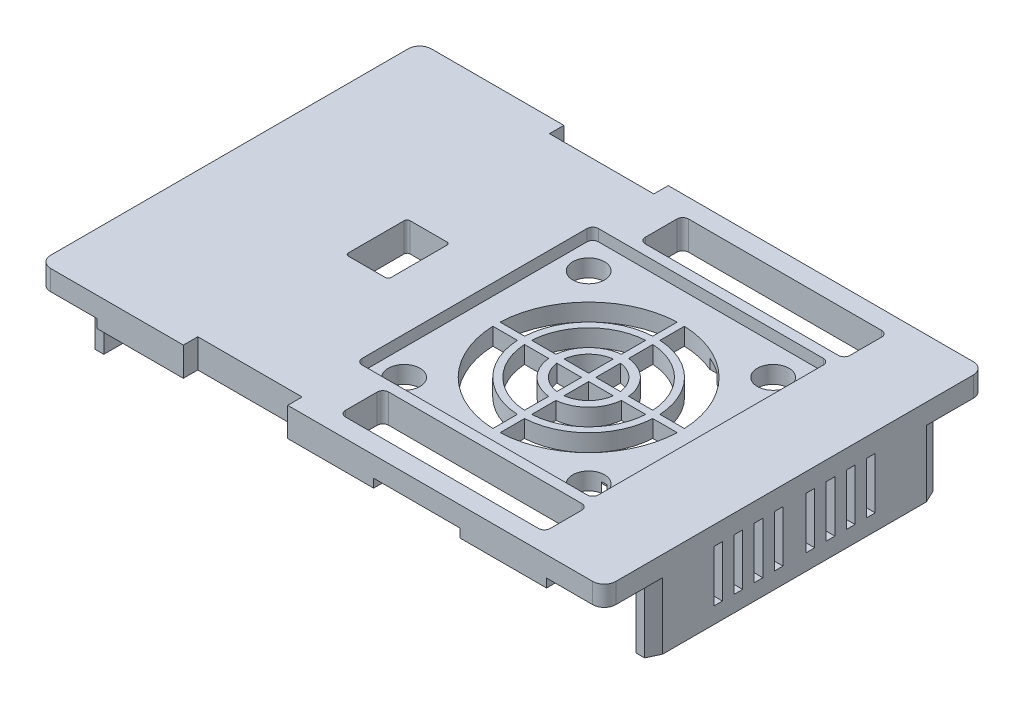
from build123d import *

# Parameters (mm, degrees)
SKETCH1_W             = 98
SKETCH1_H             = 66
BOSS_EXTRUDE1_DEPTH   = 5
SKETCH2_W             = 18.1
SKETCH2_H             = 2.5
SKETCH2_W_2           = 15
CUT_EXTRUDE1_DEPTH    = 1.5
FILLET1_R             = 2
CUT_EXTRUDE2_DEPTH    = 2
CUT_EXTRUDE3_REACH    = 5
SKETCH4_R             = 2.75
CUT_EXTRUDE4_REACH    = 7
CHAMFER1_SIZE         = 1
CHAMFER1_SIZE2        = 2.144506921
CHAMFER1_PART_2_SIZE  = 1
CHAMFER1_PART_2_SIZE2 = 2.144506921
CHAMFER1_PART_3_SIZE  = 1
CHAMFER1_PART_3_SIZE2 = 2.144506921
CHAMFER1_PART_4_SIZE  = 1
CHAMFER1_PART_4_SIZE2 = 2.144506921
BOSS_EXTRUDE2_DEPTH   = 12
FILLET2_R             = 1
BOSS_EXTRUDE3_DEPTH   = 10
CUT_EXTRUDE5_REACH    = 100
SKETCH8_W             = 1.5
SKETCH8_H             = 8.931107371
CUT_EXTRUDE6_REACH    = 19
CUT_EXTRUDE7_REACH    = 100
SKETCH10_W            = 1.5
SKETCH10_H            = 9
SKETCH13_W            = 18.1
SKETCH13_H            = 2.5
CUT_EXTRUDE9_DEPTH    = 3.5


with BuildPart() as part:
    # Sketch1 → Boss-Extrude1 (new body)
    with BuildSketch(Plane(origin=(0, 0, 0), x_dir=(1, 0, 0), z_dir=(0, 1, 0))):
        Rectangle(SKETCH1_W, SKETCH1_H)
    extrude(amount=BOSS_EXTRUDE1_DEPTH)

    # Sketch2 → Cut-Extrude1 (cut)
    with BuildSketch(Plane.XZ):
        Polygon((-39, 33), (-39, 30.5), (-46.5, 30.5), (-46.5, 24.3), (-49, 24.3), (-49, 33), align=None)
        Polygon((-46.5, -30.5), (-39, -30.5), (-39, -33), (-49, -33), (-49, -24.3), (-46.5, -24.3), align=None)
        Polygon((46.5, -30.5), (46.5, -25), (49, -25), (49, -33), (39, -33), (39, -30.5), align=None)
        with Locations((-14.95, 31.75)):
            Rectangle(SKETCH2_W, SKETCH2_H)
        with Locations((16.5, 31.75)):
            Rectangle(SKETCH2_W_2, SKETCH2_H)
        Polygon((49, 33), (39, 33), (39, 30.5), (46.5, 30.5), (46.5, 25), (49, 25), align=None)
        with Locations((16.5, -31.75)):
            Rectangle(SKETCH2_W_2, SKETCH2_H)
        with Locations((-14.95, -31.75)):
            Rectangle(SKETCH2_W, SKETCH2_H)
    extrude(amount=-CUT_EXTRUDE1_DEPTH, mode=Mode.SUBTRACT)

    # Fillet1
    fillet1_edges = [part.edges().sort_by_distance(p)[0] for p in [
        (49, 3.25, 33),
        (-49, 3.25, 33),
        (-49, 3.25, -33),
        (49, 3.25, -33),
    ]]
    fillet(fillet1_edges, radius=FILLET1_R)

    # Sketch3 → Cut-Extrude2 (cut)
    with BuildSketch(Plane(origin=(0, 5, 0), x_dir=(1, 0, 0), z_dir=(0, 1, 0))):
        with BuildLine():
            Line((-5.5, -20.5), (33.5, -20.5))
            ThreePointArc((33.5, -20.5), (34.207106781, -20.207106781), (34.5, -19.5))
            Line((34.5, -19.5), (34.5, 19.5))
            ThreePointArc((34.5, 19.5), (34.207106781, 20.207106781), (33.5, 20.5))
            Line((33.5, 20.5), (-5.5, 20.5))
            ThreePointArc((-5.5, 20.5), (-6.207106781, 20.207106781), (-6.5, 19.5))
            Line((-6.5, 19.5), (-6.5, -19.5))
            ThreePointArc((-6.5, -19.5), (-6.207106781, -20.207106781), (-5.5, -20.5))
        make_face()
    extrude(amount=-CUT_EXTRUDE2_DEPTH, mode=Mode.SUBTRACT)

    # Sketch4 → Cut-Extrude3 (cut, up to next)
    with BuildSketch(Plane(origin=(0, 3, 0), x_dir=(1, 0, 0), z_dir=(0, 1, 0)), mode=Mode.PRIVATE) as cut_extrude3_sk1:
        with Locations((30, 15.293471802)):
            Circle(SKETCH4_R)
    cut_extrude3_tool1 = extrude(cut_extrude3_sk1.sketch, amount=-CUT_EXTRUDE3_REACH, mode=Mode.PRIVATE) & part.part
    add(cut_extrude3_tool1.solids().sort_by_distance((30, 3, -15.293472))[0], mode=Mode.SUBTRACT)
    # Sketch4 → Cut-Extrude3 (cut, up to next)
    with BuildSketch(Plane(origin=(0, 3, 0), x_dir=(1, 0, 0), z_dir=(0, 1, 0)), mode=Mode.PRIVATE) as cut_extrude3_sk2:
        with Locations((30, -16.706528198)):
            Circle(SKETCH4_R)
    cut_extrude3_tool2 = extrude(cut_extrude3_sk2.sketch, amount=-CUT_EXTRUDE3_REACH, mode=Mode.PRIVATE) & part.part
    add(cut_extrude3_tool2.solids().sort_by_distance((30, 3, 16.706528))[0], mode=Mode.SUBTRACT)
    # Sketch4 → Cut-Extrude3 (cut, up to next)
    with BuildSketch(Plane(origin=(0, 3, 0), x_dir=(1, 0, 0), z_dir=(0, 1, 0)), mode=Mode.PRIVATE) as cut_extrude3_sk3:
        with Locations((-2, -16.706528198)):
            Circle(SKETCH4_R)
    cut_extrude3_tool3 = extrude(cut_extrude3_sk3.sketch, amount=-CUT_EXTRUDE3_REACH, mode=Mode.PRIVATE) & part.part
    add(cut_extrude3_tool3.solids().sort_by_distance((-2, 3, 16.706528))[0], mode=Mode.SUBTRACT)
    # Sketch4 → Cut-Extrude3 (cut, up to next)
    with BuildSketch(Plane(origin=(0, 3, 0), x_dir=(1, 0, 0), z_dir=(0, 1, 0)), mode=Mode.PRIVATE) as cut_extrude3_sk4:
        with Locations((-2, 15.293471802)):
            Circle(SKETCH4_R)
    cut_extrude3_tool4 = extrude(cut_extrude3_sk4.sketch, amount=-CUT_EXTRUDE3_REACH, mode=Mode.PRIVATE) & part.part
    add(cut_extrude3_tool4.solids().sort_by_distance((-2, 3, -15.293472))[0], mode=Mode.SUBTRACT)
    # Sketch4 → Cut-Extrude3 (cut, up to next)
    with BuildSketch(Plane(origin=(0, 3, 0), x_dir=(1, 0, 0), z_dir=(0, 1, 0)), mode=Mode.PRIVATE) as cut_extrude3_sk5:
        with BuildLine():
            Line((13.375, 5.603830139), (13.375, 9.803003365))
            ThreePointArc((13.375, 9.803003365), (6.554986366, 6.737439203), (3.490380704, -0.083005192))
            Line((3.490380704, -0.083005192), (7.689495551, -0.083005192))
            ThreePointArc((7.689495551, -0.083005192), (9.515545796, 3.776876516), (13.375, 5.603830139))
        make_face()
    cut_extrude3_tool5 = extrude(cut_extrude3_sk5.sketch, amount=-CUT_EXTRUDE3_REACH, mode=Mode.PRIVATE) & part.part
    add(cut_extrude3_tool5.solids().sort_by_distance((8.40392, 3, -4.888591))[0], mode=Mode.SUBTRACT)
    # Sketch4 → Cut-Extrude3 (cut, up to next)
    with BuildSketch(Plane(origin=(0, 3, 0), x_dir=(1, 0, 0), z_dir=(0, 1, 0)), mode=Mode.PRIVATE) as cut_extrude3_sk6:
        with BuildLine():
            Line((14.625, 11.037854092), (14.625, 15.28126011))
            ThreePointArc((14.625, 15.28126011), (25.314231081, 10.606657695), (29.987845979, -0.083005192))
            Line((29.987845979, -0.083005192), (25.744460798, -0.083005192))
            ThreePointArc((25.744460798, -0.083005192), (22.316806353, 7.609232288), (14.625, 11.037854092))
        make_face()
    cut_extrude3_tool6 = extrude(cut_extrude3_sk6.sketch, amount=-CUT_EXTRUDE3_REACH, mode=Mode.PRIVATE) & part.part
    add(cut_extrude3_tool6.solids().sort_by_distance((23.015818, 3, -8.308337))[0], mode=Mode.SUBTRACT)
    # Sketch4 → Cut-Extrude3 (cut, up to next)
    with BuildSketch(Plane(origin=(0, 3, 0), x_dir=(1, 0, 0), z_dir=(0, 1, 0)), mode=Mode.PRIVATE) as cut_extrude3_sk7:
        with BuildLine():
            Line((13.375, 11.037854092), (13.375, 15.28126011))
            ThreePointArc((13.375, 15.28126011), (2.685768919, 10.606657695), (-1.987845979, -0.083005192))
            Line((-1.987845979, -0.083005192), (2.255539202, -0.083005192))
            ThreePointArc((2.255539202, -0.083005192), (5.683193647, 7.609232288), (13.375, 11.037854092))
        make_face()
    cut_extrude3_tool7 = extrude(cut_extrude3_sk7.sketch, amount=-CUT_EXTRUDE3_REACH, mode=Mode.PRIVATE) & part.part
    add(cut_extrude3_tool7.solids().sort_by_distance((4.984182, 3, -8.308337))[0], mode=Mode.SUBTRACT)
    # Sketch4 → Cut-Extrude3 (cut, up to next)
    with BuildSketch(Plane(origin=(0, 3, 0), x_dir=(1, 0, 0), z_dir=(0, 1, 0)), mode=Mode.PRIVATE) as cut_extrude3_sk8:
        with BuildLine():
            Line((20.310504449, -0.083005192), (24.509619296, -0.083005192))
            ThreePointArc((24.509619296, -0.083005192), (21.445013634, 6.737439203), (14.625, 9.803003365))
            Line((14.625, 9.803003365), (14.625, 5.603830139))
            ThreePointArc((14.625, 5.603830139), (18.484454204, 3.776876516), (20.310504449, -0.083005192))
        make_face()
    cut_extrude3_tool8 = extrude(cut_extrude3_sk8.sketch, amount=-CUT_EXTRUDE3_REACH, mode=Mode.PRIVATE) & part.part
    add(cut_extrude3_tool8.solids().sort_by_distance((19.59608, 3, -4.888591))[0], mode=Mode.SUBTRACT)
    # Sketch4 → Cut-Extrude3 (cut, up to next)
    with BuildSketch(Plane(origin=(0, 3, 0), x_dir=(1, 0, 0), z_dir=(0, 1, 0)), mode=Mode.PRIVATE) as cut_extrude3_sk9:
        with BuildLine():
            Line((20.310504449, -1.330051205), (24.509619296, -1.330051205))
            ThreePointArc((24.509619296, -1.330051205), (21.445013634, -8.150495599), (14.625, -11.216059762))
            Line((14.625, -11.216059762), (14.625, -7.016886536))
            ThreePointArc((14.625, -7.016886536), (18.484454204, -5.189932913), (20.310504449, -1.330051205))
        make_face()
    cut_extrude3_tool9 = extrude(cut_extrude3_sk9.sketch, amount=-CUT_EXTRUDE3_REACH, mode=Mode.PRIVATE) & part.part
    add(cut_extrude3_tool9.solids().sort_by_distance((19.59608, 3, 6.301647))[0], mode=Mode.SUBTRACT)
    # Sketch4 → Cut-Extrude3 (cut, up to next)
    with BuildSketch(Plane(origin=(0, 3, 0), x_dir=(1, 0, 0), z_dir=(0, 1, 0)), mode=Mode.PRIVATE) as cut_extrude3_sk10:
        with BuildLine():
            Line((14.625, -0.083005192), (18.894017005, -0.083005192))
            ThreePointArc((18.894017005, -0.083005192), (17.489092238, 2.781511185), (14.625, 4.187300403))
            Line((14.625, 4.187300403), (14.625, -0.083005192))
        make_face()
    cut_extrude3_tool10 = extrude(cut_extrude3_sk10.sketch, amount=-CUT_EXTRUDE3_REACH, mode=Mode.PRIVATE) & part.part
    add(cut_extrude3_tool10.solids().sort_by_distance((16.367856, 3, -1.66032))[0], mode=Mode.SUBTRACT)
    # Sketch4 → Cut-Extrude3 (cut, up to next)
    with BuildSketch(Plane(origin=(0, 3, 0), x_dir=(1, 0, 0), z_dir=(0, 1, 0)), mode=Mode.PRIVATE) as cut_extrude3_sk11:
        with BuildLine():
            Line((14.625, -1.330051205), (18.894017005, -1.330051205))
            ThreePointArc((18.894017005, -1.330051205), (17.489092238, -4.194567581), (14.625, -5.6003568))
            Line((14.625, -5.6003568), (14.625, -1.330051205))
        make_face()
    cut_extrude3_tool11 = extrude(cut_extrude3_sk11.sketch, amount=-CUT_EXTRUDE3_REACH, mode=Mode.PRIVATE) & part.part
    add(cut_extrude3_tool11.solids().sort_by_distance((16.367856, 3, 3.073376))[0], mode=Mode.SUBTRACT)
    # Sketch4 → Cut-Extrude3 (cut, up to next)
    with BuildSketch(Plane(origin=(0, 3, 0), x_dir=(1, 0, 0), z_dir=(0, 1, 0)), mode=Mode.PRIVATE) as cut_extrude3_sk12:
        with BuildLine():
            Line((25.744460798, -1.330051205), (29.987845979, -1.330051205))
            ThreePointArc((29.987845979, -1.330051205), (25.314231081, -12.019714091), (14.625, -16.694316507))
            Line((14.625, -16.694316507), (14.625, -12.450910488))
            ThreePointArc((14.625, -12.450910488), (22.316806353, -9.022288685), (25.744460798, -1.330051205))
        make_face()
    cut_extrude3_tool12 = extrude(cut_extrude3_sk12.sketch, amount=-CUT_EXTRUDE3_REACH, mode=Mode.PRIVATE) & part.part
    add(cut_extrude3_tool12.solids().sort_by_distance((23.015818, 3, 9.721394))[0], mode=Mode.SUBTRACT)
    # Sketch4 → Cut-Extrude3 (cut, up to next)
    with BuildSketch(Plane(origin=(0, 3, 0), x_dir=(1, 0, 0), z_dir=(0, 1, 0)), mode=Mode.PRIVATE) as cut_extrude3_sk13:
        with BuildLine():
            Line((13.375, -16.694316507), (13.375, -12.450910488))
            ThreePointArc((13.375, -12.450910488), (5.683193647, -9.022288685), (2.255539202, -1.330051205))
            Line((2.255539202, -1.330051205), (-1.987845979, -1.330051205))
            ThreePointArc((-1.987845979, -1.330051205), (2.685768919, -12.019714091), (13.375, -16.694316507))
        make_face()
    cut_extrude3_tool13 = extrude(cut_extrude3_sk13.sketch, amount=-CUT_EXTRUDE3_REACH, mode=Mode.PRIVATE) & part.part
    add(cut_extrude3_tool13.solids().sort_by_distance((4.984182, 3, 9.721394))[0], mode=Mode.SUBTRACT)
    # Sketch4 → Cut-Extrude3 (cut, up to next)
    with BuildSketch(Plane(origin=(0, 3, 0), x_dir=(1, 0, 0), z_dir=(0, 1, 0)), mode=Mode.PRIVATE) as cut_extrude3_sk14:
        with BuildLine():
            Line((3.490380704, -1.330051205), (7.689495551, -1.330051205))
            ThreePointArc((7.689495551, -1.330051205), (9.515545796, -5.189932913), (13.375, -7.016886536))
            Line((13.375, -7.016886536), (13.375, -11.216059762))
            ThreePointArc((13.375, -11.216059762), (6.554986366, -8.150495599), (3.490380704, -1.330051205))
        make_face()
    cut_extrude3_tool14 = extrude(cut_extrude3_sk14.sketch, amount=-CUT_EXTRUDE3_REACH, mode=Mode.PRIVATE) & part.part
    add(cut_extrude3_tool14.solids().sort_by_distance((8.40392, 3, 6.301647))[0], mode=Mode.SUBTRACT)
    # Sketch4 → Cut-Extrude3 (cut, up to next)
    with BuildSketch(Plane(origin=(0, 3, 0), x_dir=(1, 0, 0), z_dir=(0, 1, 0)), mode=Mode.PRIVATE) as cut_extrude3_sk15:
        with BuildLine():
            Line((9.105982995, -0.083005192), (13.375, -0.083005192))
            Line((13.375, -0.083005192), (13.375, 4.187300403))
            ThreePointArc((13.375, 4.187300403), (10.510907762, 2.781511185), (9.105982995, -0.083005192))
        make_face()
    cut_extrude3_tool15 = extrude(cut_extrude3_sk15.sketch, amount=-CUT_EXTRUDE3_REACH, mode=Mode.PRIVATE) & part.part
    add(cut_extrude3_tool15.solids().sort_by_distance((11.632144, 3, -1.66032))[0], mode=Mode.SUBTRACT)
    # Sketch4 → Cut-Extrude3 (cut, up to next)
    with BuildSketch(Plane(origin=(0, 3, 0), x_dir=(1, 0, 0), z_dir=(0, 1, 0)), mode=Mode.PRIVATE) as cut_extrude3_sk16:
        with BuildLine():
            Line((9.105982995, -1.330051205), (13.375, -1.330051205))
            Line((13.375, -1.330051205), (13.375, -5.6003568))
            ThreePointArc((13.375, -5.6003568), (10.510907762, -4.194567581), (9.105982995, -1.330051205))
        make_face()
    cut_extrude3_tool16 = extrude(cut_extrude3_sk16.sketch, amount=-CUT_EXTRUDE3_REACH, mode=Mode.PRIVATE) & part.part
    add(cut_extrude3_tool16.solids().sort_by_distance((11.632144, 3, 3.073376))[0], mode=Mode.SUBTRACT)

    # Sketch5 → Cut-Extrude4 (cut, up to next)
    with BuildSketch(Plane(origin=(0, 5, 0), x_dir=(1, 0, 0), z_dir=(0, 1, 0)), mode=Mode.PRIVATE) as cut_extrude4_sk1:
        with BuildLine():
            Line((-16.641673729, -5.340359737), (-23.031967086, -5.340359737))
            ThreePointArc((-23.031967086, -5.340359737), (-23.385520477, -5.193913128), (-23.531967086, -4.840359737))
            Line((-23.531967086, -4.840359737), (-23.531967086, 4.840359737))
            ThreePointArc((-23.531967086, 4.840359737), (-23.385520477, 5.193913128), (-23.031967086, 5.340359737))
            Line((-23.031967086, 5.340359737), (-16.641673729, 5.340359737))
            ThreePointArc((-16.641673729, 5.340359737), (-16.288120338, 5.193913128), (-16.141673729, 4.840359737))
            Line((-16.141673729, 4.840359737), (-16.141673729, -4.840359737))
            ThreePointArc((-16.141673729, -4.840359737), (-16.288120338, -5.193913128), (-16.641673729, -5.340359737))
        make_face()
    cut_extrude4_tool1 = extrude(cut_extrude4_sk1.sketch, amount=-CUT_EXTRUDE4_REACH, mode=Mode.PRIVATE) & part.part
    add(cut_extrude4_tool1.solids().sort_by_distance((-19.83682, 5, 0))[0], mode=Mode.SUBTRACT)

    # Chamfer1
    chamfer1_edges = [part.edges().sort_by_distance(p)[0] for p in [
        (-49, 0.75, -24.3),
    ]]
    chamfer1_side = [part.faces().sort_by_distance(p)[0] for p in [
        (-47.75, 0.75, -24.3),
    ]]
    chamfer(chamfer1_edges, length=CHAMFER1_SIZE, length2=CHAMFER1_SIZE2, reference=chamfer1_side[0])

    # Chamfer1 part 2
    chamfer1_part_2_edges = [part.edges().sort_by_distance(p)[0] for p in [
        (-49, 0.75, 24.3),
    ]]
    chamfer1_part_2_side = [part.faces().sort_by_distance(p)[0] for p in [
        (-47.75, 0.75, 24.3),
    ]]
    chamfer(chamfer1_part_2_edges, length=CHAMFER1_PART_2_SIZE, length2=CHAMFER1_PART_2_SIZE2, reference=chamfer1_part_2_side[0])

    # Chamfer1 part 3
    chamfer1_part_3_edges = [part.edges().sort_by_distance(p)[0] for p in [
        (49, 0.75, -25),
    ]]
    chamfer1_part_3_side = [part.faces().sort_by_distance(p)[0] for p in [
        (47.75, 0.75, -25),
    ]]
    chamfer(chamfer1_part_3_edges, length=CHAMFER1_PART_3_SIZE, length2=CHAMFER1_PART_3_SIZE2, reference=chamfer1_part_3_side[0])

    # Chamfer1 part 4
    chamfer1_part_4_edges = [part.edges().sort_by_distance(p)[0] for p in [
        (49, 0.75, 25),
    ]]
    chamfer1_part_4_side = [part.faces().sort_by_distance(p)[0] for p in [
        (47.75, 0.75, 25),
    ]]
    chamfer(chamfer1_part_4_edges, length=CHAMFER1_PART_4_SIZE, length2=CHAMFER1_PART_4_SIZE2, reference=chamfer1_part_4_side[0])

    # Sketch6 → Boss-Extrude2 (add)
    with BuildSketch(Plane.XZ):
        Polygon((-46.5, 24.3), (-46.5, 2.3), (-49, 2.3), (-49, 22.155493079), (-48, 24.3), align=None)
    extrude(amount=BOSS_EXTRUDE2_DEPTH)

    # Fillet2
    fillet2_edges = [part.edges().sort_by_distance(p)[0] for p in [
        (-49, -6, 2.3),
    ]]
    fillet(fillet2_edges, radius=FILLET2_R)

    # Sketch7 → Boss-Extrude3 (add)
    with BuildSketch(Plane.XZ):
        Polygon((46.5, 25), (46.5, -25), (48, -25), (49, -22.855493079), (49, 22.855493079), (48, 25), align=None)
    extrude(amount=BOSS_EXTRUDE3_DEPTH)

    # Sketch8 → Cut-Extrude5 (cut, up to next)
    with BuildSketch(Plane(origin=(49, 0, 0), x_dir=(0, 0, -1), z_dir=(1, 0, 0)), mode=Mode.PRIVATE) as cut_extrude5_sk1:
        with Locations((-2.75, -2.734446314)):
            Rectangle(SKETCH8_W, SKETCH8_H)
    cut_extrude5_tool1 = extrude(cut_extrude5_sk1.sketch, amount=-CUT_EXTRUDE5_REACH, mode=Mode.PRIVATE) & part.part
    add(cut_extrude5_tool1.solids().sort_by_distance((49, -2.734446, 2.75))[0], mode=Mode.SUBTRACT)
    # Sketch8 → Cut-Extrude5 (cut, up to next)
    with BuildSketch(Plane(origin=(49, 0, 0), x_dir=(0, 0, -1), z_dir=(1, 0, 0)), mode=Mode.PRIVATE) as cut_extrude5_sk2:
        with Locations((-6.25, -2.734446314)):
            Rectangle(SKETCH8_W, SKETCH8_H)
    cut_extrude5_tool2 = extrude(cut_extrude5_sk2.sketch, amount=-CUT_EXTRUDE5_REACH, mode=Mode.PRIVATE) & part.part
    add(cut_extrude5_tool2.solids().sort_by_distance((49, -2.734446, 6.25))[0], mode=Mode.SUBTRACT)
    # Sketch8 → Cut-Extrude5 (cut, up to next)
    with BuildSketch(Plane(origin=(49, 0, 0), x_dir=(0, 0, -1), z_dir=(1, 0, 0)), mode=Mode.PRIVATE) as cut_extrude5_sk3:
        with Locations((-13.25, -2.734446314)):
            Rectangle(SKETCH8_W, SKETCH8_H)
    cut_extrude5_tool3 = extrude(cut_extrude5_sk3.sketch, amount=-CUT_EXTRUDE5_REACH, mode=Mode.PRIVATE) & part.part
    add(cut_extrude5_tool3.solids().sort_by_distance((49, -2.734446, 13.25))[0], mode=Mode.SUBTRACT)
    # Sketch8 → Cut-Extrude5 (cut, up to next)
    with BuildSketch(Plane(origin=(49, 0, 0), x_dir=(0, 0, -1), z_dir=(1, 0, 0)), mode=Mode.PRIVATE) as cut_extrude5_sk4:
        with Locations((-9.75, -2.734446314)):
            Rectangle(SKETCH8_W, SKETCH8_H)
    cut_extrude5_tool4 = extrude(cut_extrude5_sk4.sketch, amount=-CUT_EXTRUDE5_REACH, mode=Mode.PRIVATE) & part.part
    add(cut_extrude5_tool4.solids().sort_by_distance((49, -2.734446, 9.75))[0], mode=Mode.SUBTRACT)
    # Sketch8 → Cut-Extrude5 (cut, up to next)
    with BuildSketch(Plane(origin=(49, 0, 0), x_dir=(0, 0, -1), z_dir=(1, 0, 0)), mode=Mode.PRIVATE) as cut_extrude5_sk5:
        with Locations((2.75, -2.734446314)):
            Rectangle(SKETCH8_W, SKETCH8_H)
    cut_extrude5_tool5 = extrude(cut_extrude5_sk5.sketch, amount=-CUT_EXTRUDE5_REACH, mode=Mode.PRIVATE) & part.part
    add(cut_extrude5_tool5.solids().sort_by_distance((49, -2.734446, -2.75))[0], mode=Mode.SUBTRACT)
    # Sketch8 → Cut-Extrude5 (cut, up to next)
    with BuildSketch(Plane(origin=(49, 0, 0), x_dir=(0, 0, -1), z_dir=(1, 0, 0)), mode=Mode.PRIVATE) as cut_extrude5_sk6:
        with Locations((6.25, -2.734446314)):
            Rectangle(SKETCH8_W, SKETCH8_H)
    cut_extrude5_tool6 = extrude(cut_extrude5_sk6.sketch, amount=-CUT_EXTRUDE5_REACH, mode=Mode.PRIVATE) & part.part
    add(cut_extrude5_tool6.solids().sort_by_distance((49, -2.734446, -6.25))[0], mode=Mode.SUBTRACT)
    # Sketch8 → Cut-Extrude5 (cut, up to next)
    with BuildSketch(Plane(origin=(49, 0, 0), x_dir=(0, 0, -1), z_dir=(1, 0, 0)), mode=Mode.PRIVATE) as cut_extrude5_sk7:
        with Locations((9.75, -2.734446314)):
            Rectangle(SKETCH8_W, SKETCH8_H)
    cut_extrude5_tool7 = extrude(cut_extrude5_sk7.sketch, amount=-CUT_EXTRUDE5_REACH, mode=Mode.PRIVATE) & part.part
    add(cut_extrude5_tool7.solids().sort_by_distance((49, -2.734446, -9.75))[0], mode=Mode.SUBTRACT)
    # Sketch8 → Cut-Extrude5 (cut, up to next)
    with BuildSketch(Plane(origin=(49, 0, 0), x_dir=(0, 0, -1), z_dir=(1, 0, 0)), mode=Mode.PRIVATE) as cut_extrude5_sk8:
        with Locations((13.25, -2.734446314)):
            Rectangle(SKETCH8_W, SKETCH8_H)
    cut_extrude5_tool8 = extrude(cut_extrude5_sk8.sketch, amount=-CUT_EXTRUDE5_REACH, mode=Mode.PRIVATE) & part.part
    add(cut_extrude5_tool8.solids().sort_by_distance((49, -2.734446, -13.25))[0], mode=Mode.SUBTRACT)

    # Sketch9 → Cut-Extrude6 (cut, up to next)
    with BuildSketch(Plane(origin=(0, 5, 0), x_dir=(1, 0, 0), z_dir=(0, 1, 0)), mode=Mode.PRIVATE) as cut_extrude6_sk1:
        with BuildLine():
            Line((3.611771565, -22.25), (31.611771565, -22.25))
            Line((31.611771565, -22.25), (34.361771565, -22.25))
            ThreePointArc((34.361771565, -22.25), (35.068878346, -22.542893219), (35.361771565, -23.25))
            Line((35.361771565, -23.25), (35.361771565, -26))
            Line((35.361771565, -26), (35.361771565, -28.75))
            ThreePointArc((35.361771565, -28.75), (35.068878346, -29.457106781), (34.361771565, -29.75))
            Line((34.361771565, -29.75), (31.611771565, -29.75))
            Line((31.611771565, -29.75), (3.611771565, -29.75))
            Line((3.611771565, -29.75), (0.861771565, -29.75))
            ThreePointArc((0.861771565, -29.75), (0.154664783, -29.457106781), (-0.138228435, -28.75))
            Line((-0.138228435, -28.75), (-0.138228435, -23.25))
            ThreePointArc((-0.138228435, -23.25), (0.154664783, -22.542893219), (0.861771565, -22.25))
            Line((0.861771565, -22.25), (3.611771565, -22.25))
        make_face()
    cut_extrude6_tool1 = extrude(cut_extrude6_sk1.sketch, amount=-CUT_EXTRUDE6_REACH, mode=Mode.PRIVATE) & part.part
    add(cut_extrude6_tool1.solids().sort_by_distance((17.611772, 5, 26))[0], mode=Mode.SUBTRACT)
    # Sketch9 → Cut-Extrude6 (cut, up to next)
    with BuildSketch(Plane(origin=(0, 5, 0), x_dir=(1, 0, 0), z_dir=(0, 1, 0)), mode=Mode.PRIVATE) as cut_extrude6_sk2:
        with BuildLine():
            Line((31.611771565, 29.75), (34.361771565, 29.75))
            ThreePointArc((34.361771565, 29.75), (35.068878346, 29.457106781), (35.361771565, 28.75))
            Line((35.361771565, 28.75), (35.361771565, 26))
            Line((35.361771565, 26), (35.361771565, 23.25))
            ThreePointArc((35.361771565, 23.25), (35.068878346, 22.542893219), (34.361771565, 22.25))
            Line((34.361771565, 22.25), (31.611771565, 22.25))
            Line((31.611771565, 22.25), (3.611771565, 22.25))
            Line((3.611771565, 22.25), (0.861771565, 22.25))
            ThreePointArc((0.861771565, 22.25), (0.154664783, 22.542893219), (-0.138228435, 23.25))
            Line((-0.138228435, 23.25), (-0.138228435, 28.75))
            ThreePointArc((-0.138228435, 28.75), (0.154664783, 29.457106781), (0.861771565, 29.75))
            Line((0.861771565, 29.75), (3.611771565, 29.75))
            Line((3.611771565, 29.75), (31.611771565, 29.75))
        make_face()
    cut_extrude6_tool2 = extrude(cut_extrude6_sk2.sketch, amount=-CUT_EXTRUDE6_REACH, mode=Mode.PRIVATE) & part.part
    add(cut_extrude6_tool2.solids().sort_by_distance((17.611772, 5, -26))[0], mode=Mode.SUBTRACT)

    # Sketch10 → Cut-Extrude7 (cut, up to next)
    with BuildSketch(Plane.ZY.offset(49), mode=Mode.PRIVATE) as cut_extrude7_sk1:
        with Locations((9.72774654, -6)):
            Rectangle(SKETCH10_W, SKETCH10_H)
    cut_extrude7_tool1 = extrude(cut_extrude7_sk1.sketch, amount=-CUT_EXTRUDE7_REACH, mode=Mode.PRIVATE) & part.part
    add(cut_extrude7_tool1.solids().sort_by_distance((-49, -6, 9.727747))[0], mode=Mode.SUBTRACT)
    # Sketch10 → Cut-Extrude7 (cut, up to next)
    with BuildSketch(Plane.ZY.offset(49), mode=Mode.PRIVATE) as cut_extrude7_sk2:
        with Locations((12.72774654, -6)):
            Rectangle(SKETCH10_W, SKETCH10_H)
    cut_extrude7_tool2 = extrude(cut_extrude7_sk2.sketch, amount=-CUT_EXTRUDE7_REACH, mode=Mode.PRIVATE) & part.part
    add(cut_extrude7_tool2.solids().sort_by_distance((-49, -6, 12.727747))[0], mode=Mode.SUBTRACT)
    # Sketch10 → Cut-Extrude7 (cut, up to next)
    with BuildSketch(Plane.ZY.offset(49), mode=Mode.PRIVATE) as cut_extrude7_sk3:
        with Locations((15.72774654, -6)):
            Rectangle(SKETCH10_W, SKETCH10_H)
    cut_extrude7_tool3 = extrude(cut_extrude7_sk3.sketch, amount=-CUT_EXTRUDE7_REACH, mode=Mode.PRIVATE) & part.part
    add(cut_extrude7_tool3.solids().sort_by_distance((-49, -6, 15.727747))[0], mode=Mode.SUBTRACT)

    # Sketch13 → Cut-Extrude9 (cut)
    with BuildSketch(Plane.XZ.offset(-1.5)):
        with Locations((-14.95, 31.75)):
            Rectangle(SKETCH13_W, SKETCH13_H)
    cut_extrude9 = extrude(amount=-CUT_EXTRUDE9_DEPTH, mode=Mode.SUBTRACT)

    # Mirror1: Cut-Extrude9 across plane
    add(cut_extrude9.mirror(Plane.XY), mode=Mode.SUBTRACT)


solid = part.part
